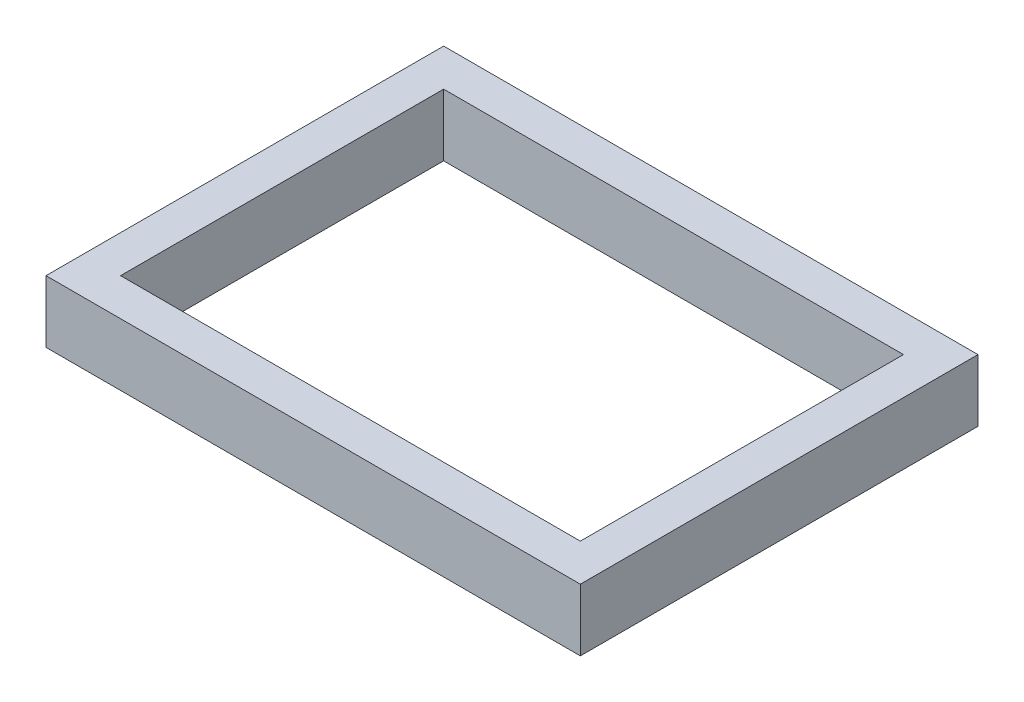
from build123d import *

# Parameters (mm, degrees)
SKETCH1_W           = 43
SKETCH1_H           = 32
SKETCH1_W_2         = 37
SKETCH1_H_2         = 26
BOSS_EXTRUDE1_DEPTH = 5


with BuildPart() as part:
    # Sketch1 → Boss-Extrude1 (new body)
    with BuildSketch(Plane(origin=(0, 0, 0), x_dir=(1, 0, 0), z_dir=(0, 1, 0))):
        with Locations((18.5, 13)):
            Rectangle(SKETCH1_W, SKETCH1_H)
        with Locations((18.5, 13)):
            Rectangle(SKETCH1_W_2, SKETCH1_H_2, mode=Mode.SUBTRACT)
    extrude(amount=BOSS_EXTRUDE1_DEPTH)


solid = part.part
